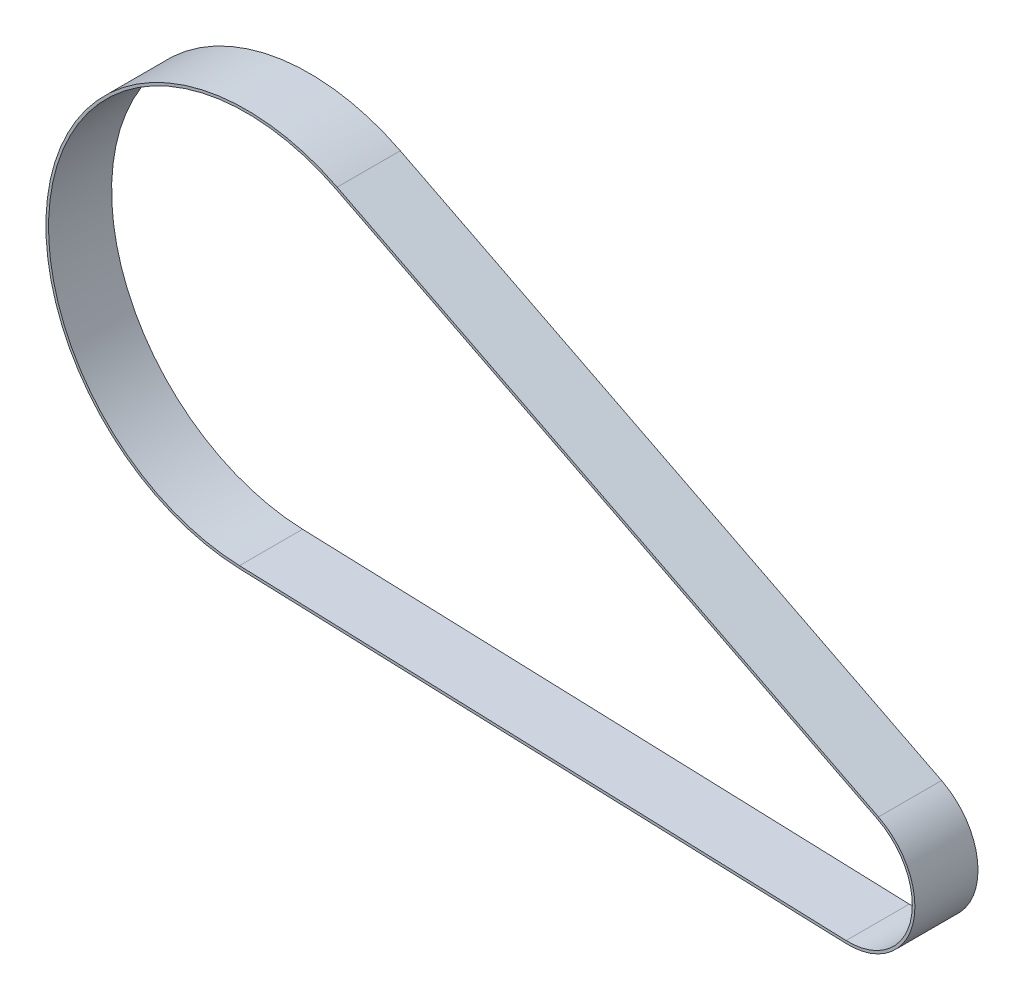
from build123d import *

# Parameters (mm, degrees)
BOSS_EXTRUDE1_DEPTH      = 3
BOSS_EXTRUDE1_DEPTH_BACK = 3


with BuildPart() as part:
    # Sketch1 → Boss-Extrude1 (new, two sides: drawn at the far end of the back side and taken through both)
    with BuildSketch(Plane.XY.offset(25.67).offset(-BOSS_EXTRUDE1_DEPTH_BACK)):
        with BuildLine():
            Line((60.116638829, -51.1464666), (8.633428278, -25.015226292))
            ThreePointArc((8.633428278, -25.015226292), (-18.470533149, -37.260691846), (-0.670439202, -61.087836182))
            Line((-0.670439202, -61.087836182), (57.029169306, -63.117088912))
            ThreePointArc((57.029169306, -63.117088912), (63.381062097, -58.371900532), (60.116638829, -51.1464666))
        make_face()
        with BuildLine():
            Line((60.003487737, -51.369394459), (8.520277187, -25.238154151))
            ThreePointArc((8.520277187, -25.238154151), (-18.228455389, -37.323128676), (-0.661652319, -60.837990648))
            Line((-0.661652319, -60.837990648), (57.037956189, -62.867243378))
            ThreePointArc((57.037956189, -62.867243378), (63.138984336, -58.309463702), (60.003487737, -51.369394459))
        make_face(mode=Mode.SUBTRACT)
    extrude(amount=BOSS_EXTRUDE1_DEPTH + BOSS_EXTRUDE1_DEPTH_BACK)


solid = part.part
